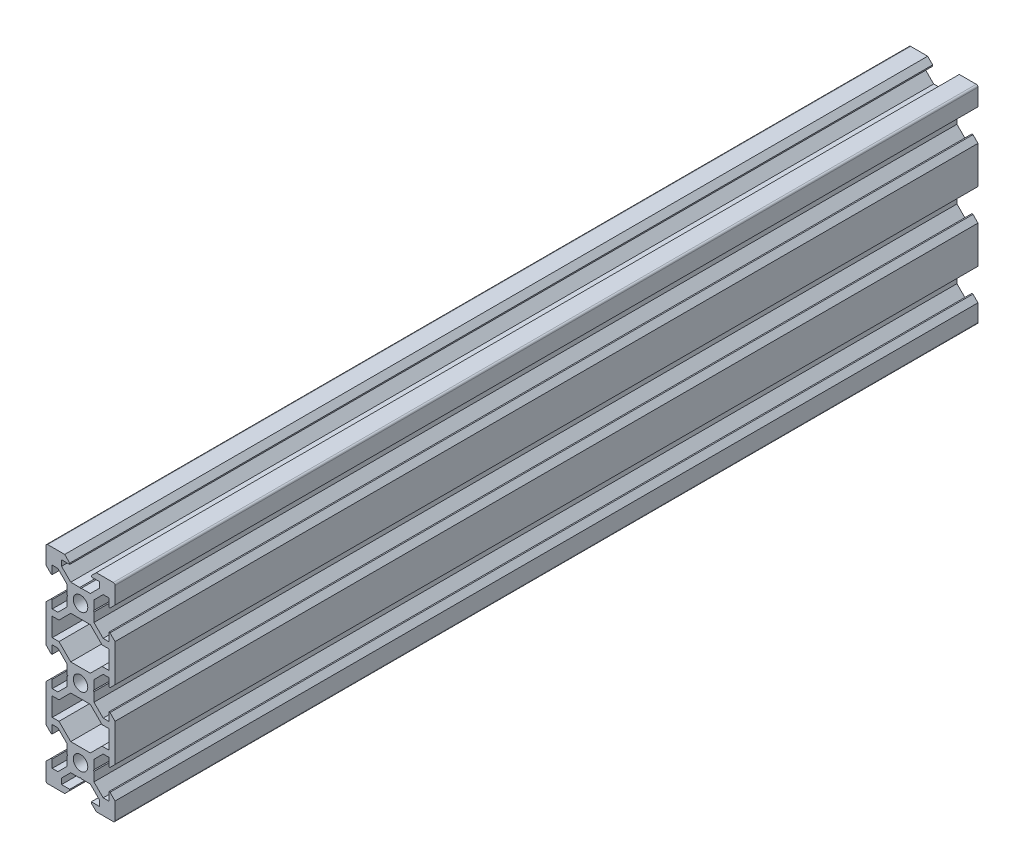
from build123d import *

# Parameters (mm, degrees)
SKETCH1_R           = 2.1
BOSS_EXTRUDE1_DEPTH = 250


with BuildPart() as part:
    # Sketch1 → Boss-Extrude1 (new body)
    with BuildSketch(Plane.XY):
        with BuildLine():
            Line((4.58, -30), (9.5, -30))
            ThreePointArc((9.5, -30), (9.853553391, -29.853553391), (10, -29.5))
            Line((10, -29.5), (10, -24.58))
            Line((10, -24.58), (8.545, -23.125))
            Line((8.545, -23.125), (8.2, -23.125))
            Line((8.2, -23.125), (8.2, -25.5))
            Line((8.2, -25.5), (6.560660172, -25.5))
            Line((6.560660172, -25.5), (3.9, -22.839339828))
            Line((3.9, -22.839339828), (3.9, -20.21))
            Line((3.9, -20.21), (3.69, -20))
            Line((3.69, -20), (3.9, -19.79))
            Line((3.9, -19.79), (3.9, -17.160660172))
            Line((3.9, -17.160660172), (6.560660172, -14.5))
            Line((6.560660172, -14.5), (8.2, -14.5))
            Line((8.2, -14.5), (8.2, -16.875))
            Line((8.2, -16.875), (8.545, -16.875))
            Line((8.545, -16.875), (10, -15.42))
            Line((10, -15.42), (10, -4.58))
            Line((10, -4.58), (8.545, -3.125))
            Line((8.545, -3.125), (8.2, -3.125))
            Line((8.2, -3.125), (8.2, -5.5))
            Line((8.2, -5.5), (6.560660172, -5.5))
            Line((6.560660172, -5.5), (3.9, -2.839339828))
            Line((3.9, -2.839339828), (3.9, -0.21))
            Line((3.9, -0.21), (3.69, 0))
            Line((3.69, 0), (3.9, 0.21))
            Line((3.9, 0.21), (3.9, 2.839339828))
            Line((3.9, 2.839339828), (6.560660172, 5.5))
            Line((6.560660172, 5.5), (8.2, 5.5))
            Line((8.2, 5.5), (8.2, 3.125))
            Line((8.2, 3.125), (8.545, 3.125))
            Line((8.545, 3.125), (10, 4.58))
            Line((10, 4.58), (10, 15.42))
            Line((10, 15.42), (8.545, 16.875))
            Line((8.545, 16.875), (8.2, 16.875))
            Line((8.2, 16.875), (8.2, 14.5))
            Line((8.2, 14.5), (6.560660172, 14.5))
            Line((6.560660172, 14.5), (3.9, 17.160660172))
            Line((3.9, 17.160660172), (3.9, 19.79))
            Line((3.9, 19.79), (3.69, 20))
            Line((3.69, 20), (3.9, 20.21))
            Line((3.9, 20.21), (3.9, 22.839339828))
            Line((3.9, 22.839339828), (6.560660172, 25.5))
            Line((6.560660172, 25.5), (8.2, 25.5))
            Line((8.2, 25.5), (8.2, 23.125))
            Line((8.2, 23.125), (8.545, 23.125))
            Line((8.545, 23.125), (10, 24.58))
            Line((10, 24.58), (10, 29.5))
            ThreePointArc((10, 29.5), (9.853553391, 29.853553391), (9.5, 30))
            Line((9.5, 30), (4.58, 30))
            Line((4.58, 30), (3.125, 28.545))
            Line((3.125, 28.545), (3.125, 28.2))
            Line((3.125, 28.2), (5.5, 28.2))
            Line((5.5, 28.2), (5.5, 26.560660172))
            Line((5.5, 26.560660172), (2.839339828, 23.9))
            Line((2.839339828, 23.9), (0.21, 23.9))
            Line((0.21, 23.9), (0, 23.69))
            Line((0, 23.69), (-0.21, 23.9))
            Line((-0.21, 23.9), (-2.839339828, 23.9))
            Line((-2.839339828, 23.9), (-5.5, 26.560660172))
            Line((-5.5, 26.560660172), (-5.5, 28.2))
            Line((-5.5, 28.2), (-3.125, 28.2))
            Line((-3.125, 28.2), (-3.125, 28.545))
            Line((-3.125, 28.545), (-4.58, 30))
            Line((-4.58, 30), (-9.5, 30))
            ThreePointArc((-9.5, 30), (-9.853553391, 29.853553391), (-10, 29.5))
            Line((-10, 29.5), (-10, 24.58))
            Line((-10, 24.58), (-8.545, 23.125))
            Line((-8.545, 23.125), (-8.2, 23.125))
            Line((-8.2, 23.125), (-8.2, 25.5))
            Line((-8.2, 25.5), (-6.560660172, 25.5))
            Line((-6.560660172, 25.5), (-3.9, 22.839339828))
            Line((-3.9, 22.839339828), (-3.9, 20.21))
            Line((-3.9, 20.21), (-3.69, 20))
            Line((-3.69, 20), (-3.9, 19.79))
            Line((-3.9, 19.79), (-3.9, 17.160660172))
            Line((-3.9, 17.160660172), (-6.560660172, 14.5))
            Line((-6.560660172, 14.5), (-8.2, 14.5))
            Line((-8.2, 14.5), (-8.2, 16.875))
            Line((-8.2, 16.875), (-8.545, 16.875))
            Line((-8.545, 16.875), (-10, 15.42))
            Line((-10, 15.42), (-10, 4.58))
            Line((-10, 4.58), (-8.545, 3.125))
            Line((-8.545, 3.125), (-8.2, 3.125))
            Line((-8.2, 3.125), (-8.2, 5.5))
            Line((-8.2, 5.5), (-6.560660172, 5.5))
            Line((-6.560660172, 5.5), (-3.9, 2.839339828))
            Line((-3.9, 2.839339828), (-3.9, 0.21))
            Line((-3.9, 0.21), (-3.69, 0))
            Line((-3.69, 0), (-3.9, -0.21))
            Line((-3.9, -0.21), (-3.9, -2.839339828))
            Line((-3.9, -2.839339828), (-6.560660172, -5.5))
            Line((-6.560660172, -5.5), (-8.2, -5.5))
            Line((-8.2, -5.5), (-8.2, -3.125))
            Line((-8.2, -3.125), (-8.545, -3.125))
            Line((-8.545, -3.125), (-10, -4.58))
            Line((-10, -4.58), (-10, -15.42))
            Line((-10, -15.42), (-8.545, -16.875))
            Line((-8.545, -16.875), (-8.2, -16.875))
            Line((-8.2, -16.875), (-8.2, -14.5))
            Line((-8.2, -14.5), (-6.560660172, -14.5))
            Line((-6.560660172, -14.5), (-3.9, -17.160660172))
            Line((-3.9, -17.160660172), (-3.9, -19.79))
            Line((-3.9, -19.79), (-3.69, -20))
            Line((-3.69, -20), (-3.9, -20.21))
            Line((-3.9, -20.21), (-3.9, -22.839339828))
            Line((-3.9, -22.839339828), (-6.560660172, -25.5))
            Line((-6.560660172, -25.5), (-8.2, -25.5))
            Line((-8.2, -25.5), (-8.2, -23.125))
            Line((-8.2, -23.125), (-8.545, -23.125))
            Line((-8.545, -23.125), (-10, -24.58))
            Line((-10, -24.58), (-10, -29.5))
            ThreePointArc((-10, -29.5), (-9.853553391, -29.853553391), (-9.5, -30))
            Line((-9.5, -30), (-4.58, -30))
            Line((-4.58, -30), (-3.125, -28.545))
            Line((-3.125, -28.545), (-3.125, -28.2))
            Line((-3.125, -28.2), (-5.5, -28.2))
            Line((-5.5, -28.2), (-5.5, -26.560660172))
            Line((-5.5, -26.560660172), (-2.839339828, -23.9))
            Line((-2.839339828, -23.9), (-0.21, -23.9))
            Line((-0.21, -23.9), (0, -23.69))
            Line((0, -23.69), (0.21, -23.9))
            Line((0.21, -23.9), (2.839339828, -23.9))
            Line((2.839339828, -23.9), (5.5, -26.560660172))
            Line((5.5, -26.560660172), (5.5, -28.2))
            Line((5.5, -28.2), (3.125, -28.2))
            Line((3.125, -28.2), (3.125, -28.545))
            Line((3.125, -28.545), (4.58, -30))
        make_face()
        with Locations((0, -20)):
            Circle(SKETCH1_R, mode=Mode.SUBTRACT)
        Polygon((-6.239339828, -12.7), (-8.2, -12.7), (-8.2, -7.3), (-6.239339828, -7.3), (-2.839339828, -3.9), (2.839339828, -3.9), (6.239339828, -7.3), (8.2, -7.3), (8.2, -12.7), (6.239339828, -12.7), (2.839339828, -16.1), (-2.839339828, -16.1), align=None, mode=Mode.SUBTRACT)
        Polygon((-6.239339828, 7.3), (-8.2, 7.3), (-8.2, 12.7), (-6.239339828, 12.7), (-2.839339828, 16.1), (2.839339828, 16.1), (6.239339828, 12.7), (8.2, 12.7), (8.2, 7.3), (6.239339828, 7.3), (2.839339828, 3.9), (-2.839339828, 3.9), align=None, mode=Mode.SUBTRACT)
        with Locations((0, 20)):
            Circle(SKETCH1_R, mode=Mode.SUBTRACT)
        Circle(SKETCH1_R, mode=Mode.SUBTRACT)
    extrude(amount=BOSS_EXTRUDE1_DEPTH)


solid = part.part
